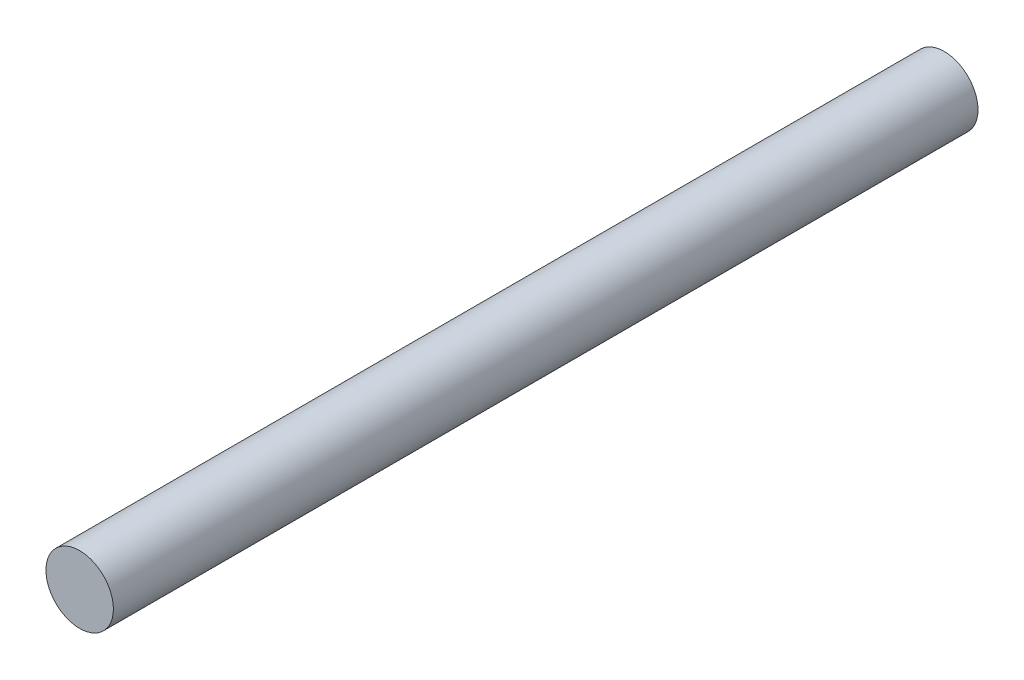
from build123d import *

# Parameters (mm, degrees)
SKETCH1_R           = 39
BOSS_EXTRUDE1_DEPTH = 500


with BuildPart() as part:
    # Sketch1 → Boss-Extrude1 (new body, symmetric)
    with BuildSketch(Plane.XY):
        Circle(SKETCH1_R)
    extrude(amount=BOSS_EXTRUDE1_DEPTH, both=True)


solid = part.part
